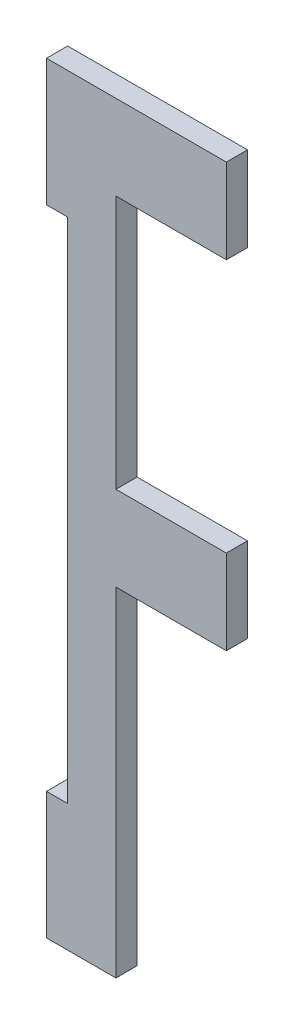
from build123d import *

# Parameters (mm, degrees)
BOSS_EXTRUDE1_DEPTH = 3.175


with BuildPart() as part:
    # Sketch1 → Boss-Extrude1 (new body)
    with BuildSketch(Plane.XY):
        Polygon((-3.175, -95.25), (7.239, -95.25), (7.239, -44.45), (23.8125, -44.45), (23.8125, -31.75), (7.239, -31.75), (7.239, 6.35), (23.8125, 6.35), (23.8125, 19.05), (-3.175, 19.05), (-3.175, 0), (0, 0), (0, -76.2), (-3.175, -76.2), align=None)
    extrude(amount=BOSS_EXTRUDE1_DEPTH)


solid = part.part
